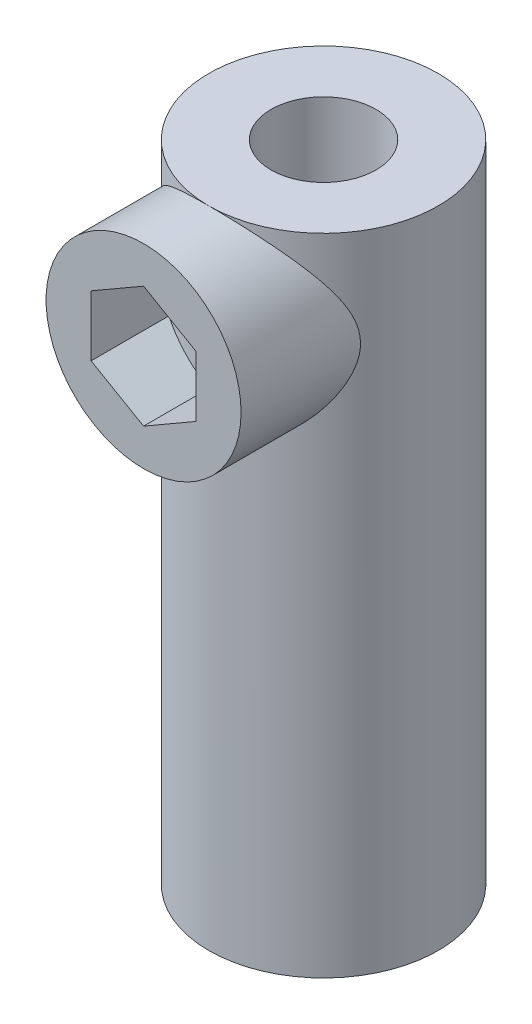
from build123d import *

# Parameters (mm, degrees)
CROQUIS1_R                   = 7.65
SALIENTE_EXTRUIR1_DEPTH      = 8.5
CROQUIS2_R                   = 7.65
CROQUIS2_R_2                 = 3.5
SALIENTE_EXTRUIR2_DEPTH      = 21.5
SALIENTE_EXTRUIR3_REACH      = 132.896
SALIENTE_EXTRUIR3_END_RADIUS = 7.65
SALIENTE_EXTRUIR3_START      = 12
CROQUIS3_R                   = 6.5
CORTAR_EXTRUIR1_REACH        = 129.309
CORTAR_EXTRUIR1_END_RADIUS   = 3.5
CROQUIS4_R                   = 2.25


with BuildPart() as part:
    # Croquis1 → Saliente-Extruir1 (new, symmetric)
    with BuildSketch(Plane(origin=(0, 0, 0), x_dir=(1, 0, 0), z_dir=(0, 1, 0))):
        with BuildLine():
            ThreePointArc((-18.62950636, 70.733830846), (-21.266037972, 78.379045573), (-29.224003483, 79.818278736))
            ThreePointArc((-29.224003483, 79.818278736), (-42.5, 73.612159322), (-54.51265533, 65.217868785))
            ThreePointArc((-54.51265533, 65.217868785), (-57.245225604, 57.606451909), (-51.942541239, 51.500541191))
            ThreePointArc((-51.942541239, 51.500541191), (-41.569219382, 24), (-70.572047599, 19.233289655))
            ThreePointArc((-70.572047599, 19.233289655), (-78.511263577, 20.772593665), (-83.736658814, 14.600409951))
            ThreePointArc((-83.736658814, 14.600409951), (-85, 0), (-83.736658814, -14.600409951))
            ThreePointArc((-83.736658814, -14.600409951), (-78.511263577, -20.772593665), (-70.572047599, -19.233289655))
            ThreePointArc((-70.572047599, -19.233289655), (-41.569219382, -24), (-51.942541239, -51.500541191))
            ThreePointArc((-51.942541239, -51.500541191), (-57.245225604, -57.606451909), (-54.51265533, -65.217868785))
            ThreePointArc((-54.51265533, -65.217868785), (-42.5, -73.612159322), (-29.224003483, -79.818278736))
            ThreePointArc((-29.224003483, -79.818278736), (-21.266037972, -78.379045573), (-18.62950636, -70.733830846))
            ThreePointArc((-18.62950636, -70.733830846), (0, -48), (18.62950636, -70.733830846))
            ThreePointArc((18.62950636, -70.733830846), (21.266037972, -78.379045573), (29.224003483, -79.818278736))
            ThreePointArc((29.224003483, -79.818278736), (42.5, -73.612159322), (54.51265533, -65.217868785))
            ThreePointArc((54.51265533, -65.217868785), (57.245225604, -57.606451909), (51.942541239, -51.500541191))
            ThreePointArc((51.942541239, -51.500541191), (41.569219382, -24), (70.572047599, -19.233289655))
            ThreePointArc((70.572047599, -19.233289655), (78.511263577, -20.772593665), (83.736658814, -14.600409951))
            ThreePointArc((83.736658814, -14.600409951), (85, 0), (83.736658814, 14.600409951))
            ThreePointArc((83.736658814, 14.600409951), (78.511263577, 20.772593665), (70.572047599, 19.233289655))
            ThreePointArc((70.572047599, 19.233289655), (41.569219382, 24), (51.942541239, 51.500541191))
            ThreePointArc((51.942541239, 51.500541191), (57.245225604, 57.606451909), (54.51265533, 65.217868785))
            ThreePointArc((54.51265533, 65.217868785), (42.5, 73.612159322), (29.224003483, 79.818278736))
            ThreePointArc((29.224003483, 79.818278736), (21.266037972, 78.379045573), (18.62950636, 70.733830846))
            ThreePointArc((18.62950636, 70.733830846), (0, 48), (-18.62950636, 70.733830846))
        make_face()
        with Locations(Location((0, 0, 0), (0, 0, 270))):
            Circle(CROQUIS1_R, mode=Mode.SUBTRACT)
    extrude(amount=SALIENTE_EXTRUIR1_DEPTH, both=True)


with BuildPart() as body_2:
    # Croquis2 → Saliente-Extruir2 (new body)
    with BuildSketch(Plane(origin=(0, 0, 0), x_dir=(1, 0, 0), z_dir=(0, 1, 0))):
        with Locations(Location((0, 0, 0), (0, 0, 270))):
            Circle(CROQUIS2_R)
        with Locations(Location((0, 0, 0), (0, 0, 270))):
            Circle(CROQUIS2_R_2, mode=Mode.SUBTRACT)
    extrude(amount=SALIENTE_EXTRUIR2_DEPTH)

    # Simetría3: body 2 across plane


with BuildPart() as body_2_1:
    add(body_2.part)
    add(body_2.part.mirror(Plane.ZX))

    # Saliente-Extruir3: up to this cylinder (the profile starts outside it)
    saliente_extruir3_end = Plane(origin=(0, 15, 0), z_dir=(0, -1, 0)) * Cylinder(SALIENTE_EXTRUIR3_END_RADIUS, 282.092, mode=Mode.PRIVATE)
    # Croquis3 → Saliente-Extruir3 (add, up to the surface)
    with BuildSketch(Plane.XY.offset(SALIENTE_EXTRUIR3_START), mode=Mode.PRIVATE) as saliente_extruir3_sk1:
        with Locations((0, 15)):
            Circle(CROQUIS3_R)
        Polygon((0, 10.958548116), (3.5, 12.979274058), (3.5, 17.020725942), (0, 19.041451884), (-3.5, 17.020725942), (-3.5, 12.979274058), align=None, mode=Mode.SUBTRACT)
    saliente_extruir3_tool1 = extrude(saliente_extruir3_sk1.sketch, amount=-SALIENTE_EXTRUIR3_REACH, mode=Mode.PRIVATE) - saliente_extruir3_end
    add(saliente_extruir3_tool1.solids().sort_by_distance((-6.316152, 15, 12))[0])

    # Cortar-Extruir1: up to this cylinder (the profile starts outside it)
    cortar_extruir1_end = Plane(origin=(0, 15, 0), z_dir=(0, -1, 0)) * Cylinder(CORTAR_EXTRUIR1_END_RADIUS, 266.618, mode=Mode.PRIVATE)
    # Croquis4 → Cortar-Extruir1 (cut, up to the surface)
    with BuildSketch(Plane.XY.offset(12), mode=Mode.PRIVATE) as cortar_extruir1_sk1:
        with Locations((0, 15)):
            Circle(CROQUIS4_R)
    cortar_extruir1_tool1 = extrude(cortar_extruir1_sk1.sketch, amount=-CORTAR_EXTRUIR1_REACH, mode=Mode.PRIVATE) - cortar_extruir1_end
    add(cortar_extruir1_tool1.solids().sort_by_distance((0, 15, 12))[0], mode=Mode.SUBTRACT)


solid = body_2_1.part
